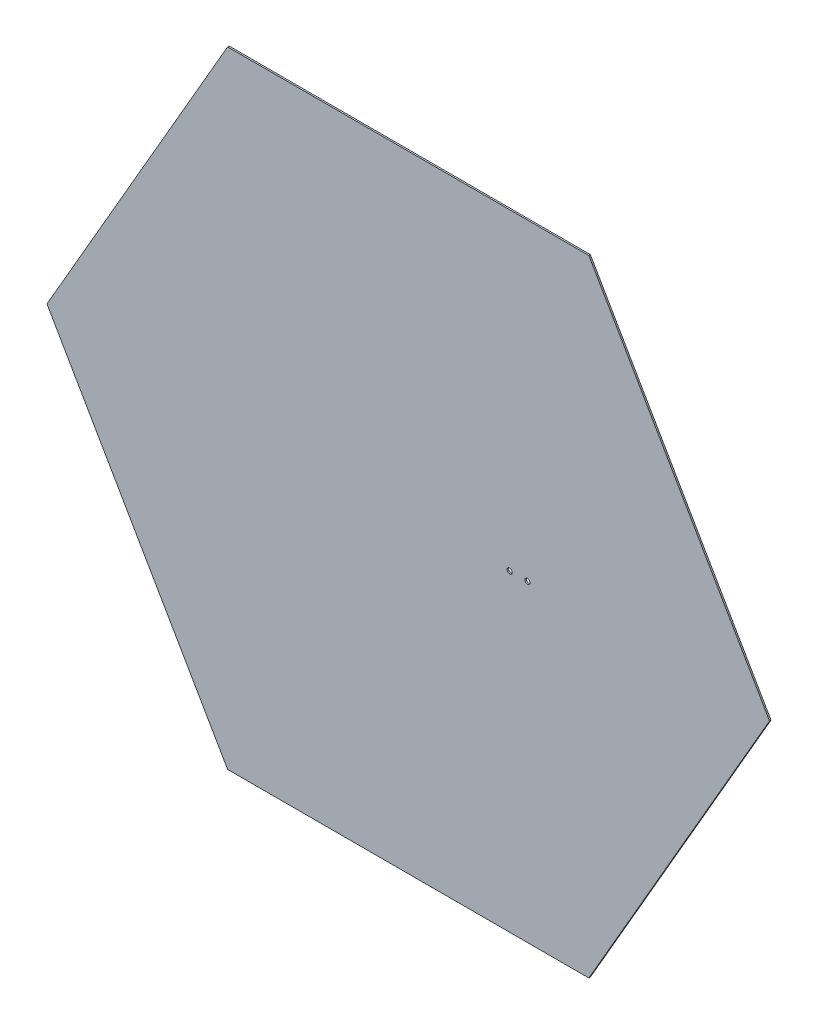
from build123d import *

# Parameters (mm, degrees)
SALIENTE_EXTRUIR1_DEPTH = 1.65
CROQUIS2_R              = 2.75
CORTAR_EXTRUIR1_DEPTH   = 2.65


with BuildPart() as part:
    # Croquis1 → Saliente-Extruir1 (new body)
    with BuildSketch(Plane.XY):
        Polygon((194.393835636, 336.7), (-194.393835636, 336.7), (-388.787671272, 0), (-194.393835636, -336.7), (194.393835636, -336.7), (388.787671272, 0), align=None)
    extrude(amount=SALIENTE_EXTRUIR1_DEPTH)

    # Croquis2 → Cortar-Extruir1 (cut, through all)
    with BuildSketch(Plane(origin=(0, 0, 0), x_dir=(-1, 0, 0), z_dir=(0, 0, -1))):
        with Locations((-128.25, 0)):
            Circle(CROQUIS2_R)
        with Locations((-109.15, 0)):
            Circle(CROQUIS2_R)
    extrude(amount=-CORTAR_EXTRUIR1_DEPTH, mode=Mode.SUBTRACT)


solid = part.part
